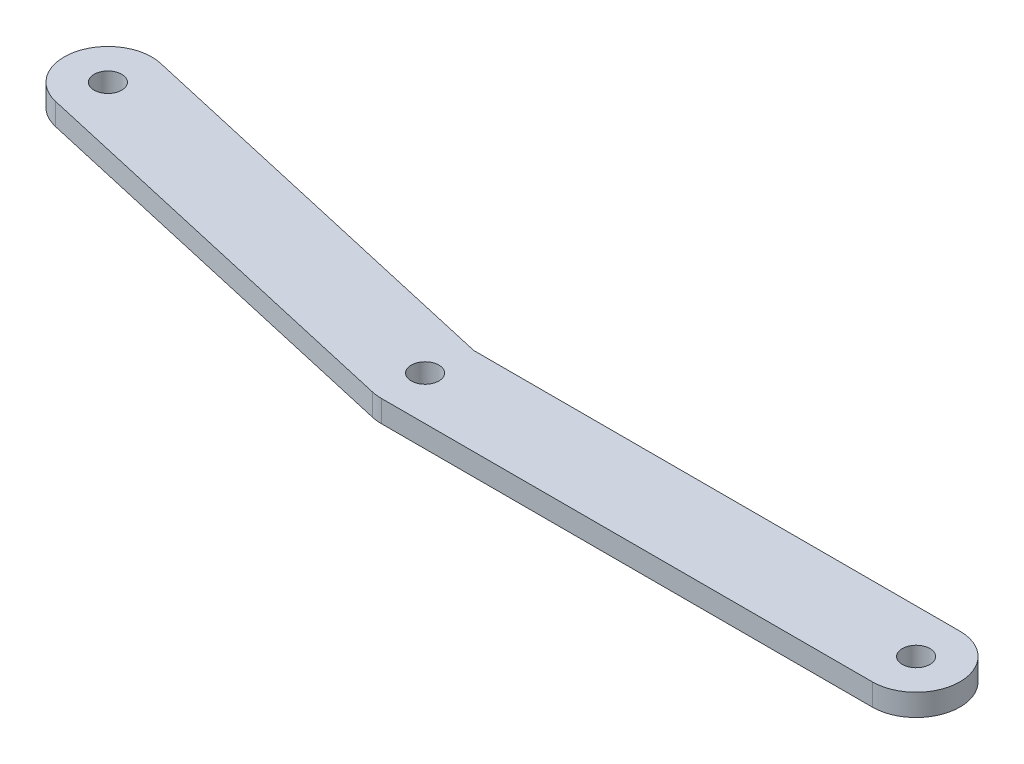
from build123d import *

# Parameters (mm, degrees)
SKETCH2_R               = 2.000000064
BOSS_EXTRUDE2_DEPTH     = 3.175
SKETCH1_R               = 2.000000064
BOSS_EXTRUDE3_DEPTH     = 3.175
SKETCH3_R               = 2.000000064
CUT_EXTRUDE1_DEPTH      = 1
CUT_EXTRUDE1_DEPTH_BACK = 4.175


with BuildPart() as part:
    # Sketch2 → Boss-Extrude2 (new body)
    with BuildSketch(Plane(origin=(0, 0, 0), x_dir=(1, 0, 0), z_dir=(0, 1, 0))):
        with BuildLine():
            Line((-36.96683296, -6.1921984), (-96.411937598, 7.313398015))
            ThreePointArc((-96.411937598, 7.313398015), (-101.197303038, 14.912429375), (-93.598271679, 19.697794815))
            Line((-93.598271679, 19.697794815), (-34.15316704, 6.1921984))
            ThreePointArc((-34.15316704, 6.1921984), (-29.3678016, -1.40683296), (-36.96683296, -6.1921984))
        make_face()
        with Locations((-95.005104638, 13.505596415)):
            Circle(SKETCH2_R, mode=Mode.SUBTRACT)
    extrude(amount=BOSS_EXTRUDE2_DEPTH)

    # Sketch1 → Boss-Extrude3 (add)
    with BuildSketch(Plane(origin=(0, 0, 0), x_dir=(1, 0, 0), z_dir=(0, 1, 0))):
        with BuildLine():
            Line((-35.56, 6.35), (35.56, 6.35))
            ThreePointArc((35.56, 6.35), (41.91, 0), (35.56, -6.35))
            Line((35.56, -6.35), (-35.56, -6.35))
            ThreePointArc((-35.56, -6.35), (-41.91, 0), (-35.56, 6.35))
        make_face()
        with Locations((35.56, 0)):
            Circle(SKETCH1_R, mode=Mode.SUBTRACT)
    extrude(amount=BOSS_EXTRUDE3_DEPTH)

    # Sketch3 → Cut-Extrude1 (cut, two sides)
    with BuildSketch(Plane(origin=(0, 3.175, 0), x_dir=(1, 0, 0), z_dir=(0, 1, 0))) as cut_extrude1_sk:
        with Locations((-35.56, 0)):
            Circle(SKETCH3_R)
    extrude(amount=CUT_EXTRUDE1_DEPTH, mode=Mode.SUBTRACT)
    extrude(cut_extrude1_sk.sketch, amount=-CUT_EXTRUDE1_DEPTH_BACK, mode=Mode.SUBTRACT)


solid = part.part
